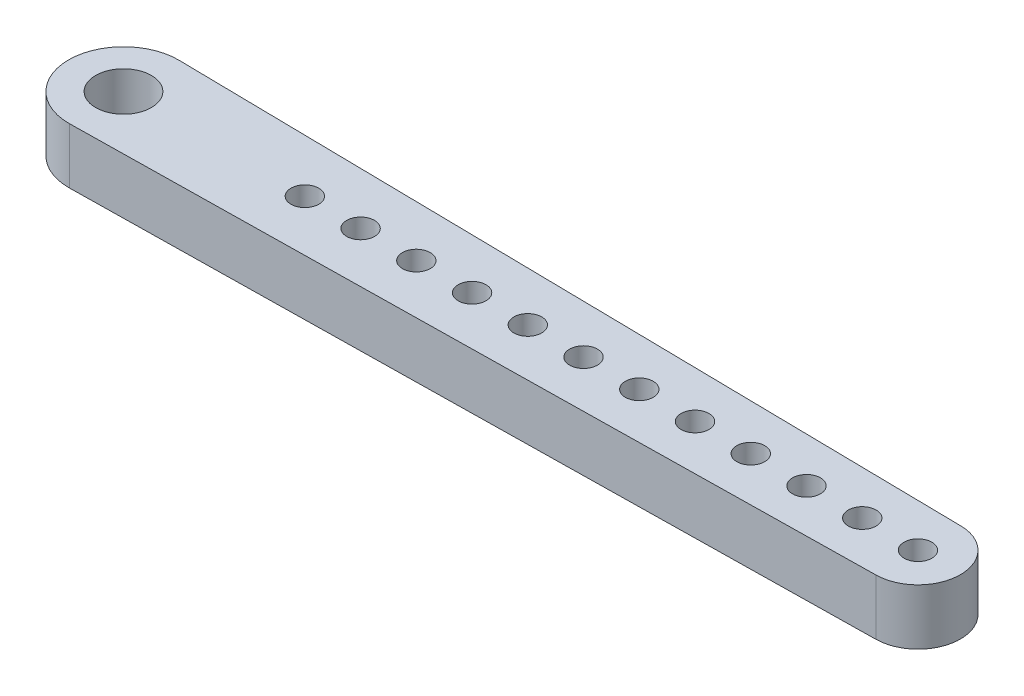
from build123d import *

# Parameters (mm, degrees)
BOSS_EXTRUDE1_DEPTH = 6.35
FILLET1_R           = 4.837495
FILLET3_R           = 6.251556
SKETCH3_R           = 3.175
SKETCH3_R_2         = 1.5875
CUT_EXTRUDE1_DEPTH  = 7.35
SKETCH5_R           = 1.5875
CUT_EXTRUDE2_DEPTH  = 7.35
LPATTERN1_COUNT     = 11
LPATTERN1_PITCH     = 6.35


with BuildPart() as part:
    # Sketch2 → Boss-Extrude1 (new body)
    with BuildSketch(Plane(origin=(0, 0, 0), x_dir=(1, 0, 0), z_dir=(0, 1, 0))):
        Polygon((0, 0), (0, 6.35), (101.6, 4.7625), (101.6, 0), align=None)
    boss_extrude1 = extrude(amount=BOSS_EXTRUDE1_DEPTH)

    # Mirror1: Boss-Extrude1 across plane
    add(boss_extrude1.mirror(Plane(origin=(101.6, 6.35, 0), x_dir=(1, 0, 0), z_dir=(0, 0, -1))))

    # Fillet1
    fillet1_edges = [part.edges().sort_by_distance(p)[0] for p in [
        (101.6, 3.175, 4.7625),
        (101.6, 3.175, -4.7625),
    ]]
    fillet(fillet1_edges, radius=FILLET1_R)

    # Fillet3
    fillet3_edges = [part.edges().sort_by_distance(p)[0] for p in [
        (0, 3.175, 6.35),
        (0, 3.175, -6.35),
    ]]
    fillet(fillet3_edges, radius=FILLET3_R)

    # Sketch3 → Cut-Extrude1 (cut, through all)
    with BuildSketch(Plane(origin=(0, 6.35, 0), x_dir=(1, 0, 0), z_dir=(0, 1, 0))):
        with Locations((6.251556349, 0)):
            Circle(SKETCH3_R)
        with Locations((96.762504613, 0)):
            Circle(SKETCH3_R_2)
    extrude(amount=-CUT_EXTRUDE1_DEPTH, mode=Mode.SUBTRACT)

    # Sketch5 → Cut-Extrude2 (cut, through all)
    with BuildSketch(Plane(origin=(0, 6.35, 0), x_dir=(1, 0, 0), z_dir=(0, 1, 0))):
        with Locations((90.412504613, 0)):
            Circle(SKETCH5_R)
    cut_extrude2 = extrude(amount=-CUT_EXTRUDE2_DEPTH, mode=Mode.SUBTRACT)

    # LPattern1: Cut-Extrude2 ×11
    with Locations(*[(-i * LPATTERN1_PITCH, 0, 0) for i in range(1, LPATTERN1_COUNT)]):
        add(cut_extrude2, mode=Mode.SUBTRACT)


solid = part.part
